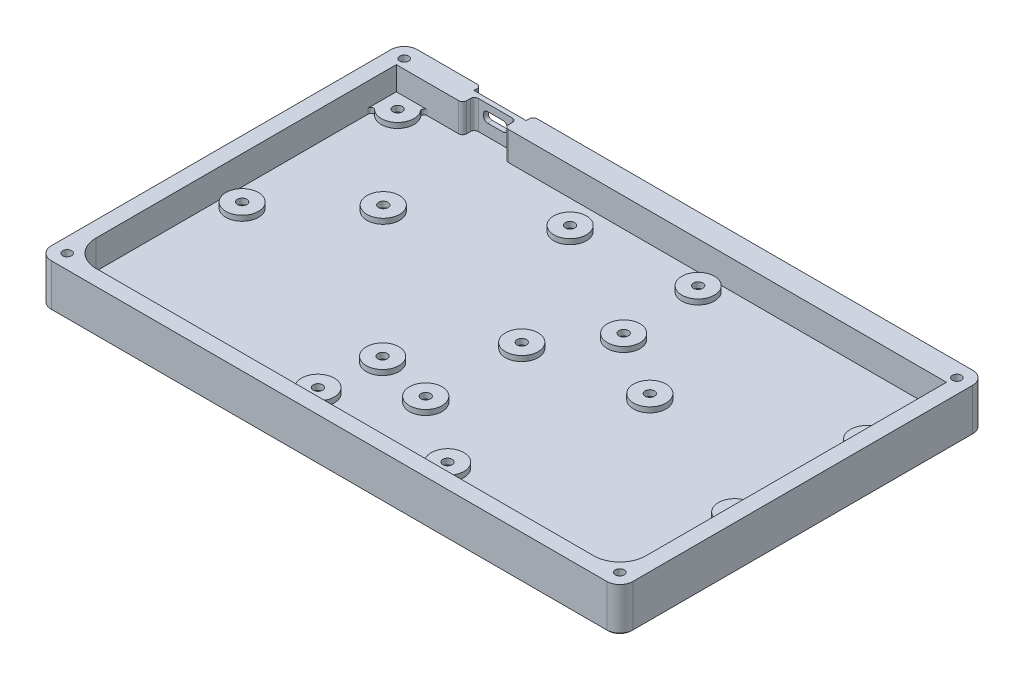
from build123d import *

# Parameters (mm, degrees)
SKETCH1_W                                      = 222.53
SKETCH1_H                                      = 140
BASEPLATE_DEPTH                                = 5.6
SKETCH2_W                                      = 222.53
SKETCH2_H                                      = 140
SIDEWALLS_DEPTH                                = 11
SKETCH3_W                                      = 16
SKETCH3_H                                      = 4.5
USB_RELIEF_DEPTH                               = 11
SKETCH6_R                                      = 6.25
PCB_SUPPORT_DEPTH                              = 2
SKETCH15_W                                     = 6
SKETCH15_H                                     = 5.5
CORNER_FILL_DEPTH                              = 2
FILLET3_R                                      = 1
NUT_START                                      = -0.2
SKETCH4_W                                      = 5.8
SKETCH4_H                                      = 5.8
NUT_CUTOUT_DEPTH                               = 1.8
THIN_USB_WALL_REACH                            = 8.3
THIN_START                                     = -1.8
M3_CLEARANCE_HOLE1_D                           = 3.6
M3_CLEARANCE_HOLE1_DEPTH                       = 2.418450886
M3_CLEARANCE_HOLE1_TIP                         = 1.081549114
CSK_FOR_M3_FLAT_HEAD_MACHINE_SCREW1_AT_2_COUNT = 2
CSK_FOR_M3_FLAT_HEAD_MACHINE_SCREW1_AT_2_PITCH = 211.53
CSK_FOR_M3_FLAT_HEAD_MACHINE_SCREW1_AT_3_COUNT = 2
CSK_FOR_M3_FLAT_HEAD_MACHINE_SCREW1_AT_3_PITCH = 247.761863288
CSK_FOR_M3_FLAT_HEAD_MACHINE_SCREW1_AT_4_COUNT = 2
CSK_FOR_M3_FLAT_HEAD_MACHINE_SCREW1_AT_4_PITCH = 129
USB_PORT_REACH                                 = 139.3
FILLET1_R                                      = 5
FILLET2_R                                      = 1.5
SKETCH13_W                                     = 200
SKETCH13_H                                     = 120
CUT_EXTRUDE1_DEPTH                             = 2.6
CHAMFER1_SIZE                                  = 0.5


with BuildPart() as part:
    # Sketch1 → Baseplate (new body)
    with BuildSketch(Plane(origin=(0, 0, 0), x_dir=(1, 0, 0), z_dir=(0, 1, 0))):
        with Locations((111.265, 70)):
            Rectangle(SKETCH1_W, SKETCH1_H)
    extrude(amount=BASEPLATE_DEPTH)

    # Sketch2 → Sidewalls (add)
    with BuildSketch(Plane(origin=(0, 5.6, 0), x_dir=(1, 0, 0), z_dir=(0, 1, 0))):
        with Locations((111.265, 70)):
            Rectangle(SKETCH2_W, SKETCH2_H)
        with BuildLine():
            Line((206.53, 6), (16, 6))
            ThreePointArc((16, 6), (8.928932188, 8.928932188), (6, 16))
            Line((6, 16), (6, 131))
            Line((6, 131), (216.53, 131))
            Line((216.53, 131), (216.53, 16))
            ThreePointArc((216.53, 16), (213.601067812, 8.928932188), (206.53, 6))
        make_face(mode=Mode.SUBTRACT)
    extrude(amount=SIDEWALLS_DEPTH)

    # Sketch3 → USB Relief (cut)
    with BuildSketch(Plane(origin=(0, 16.6, 0), x_dir=(1, 0, 0), z_dir=(0, 1, 0))):
        with Locations((39.38, 133.25)):
            Rectangle(SKETCH3_W, SKETCH3_H)
    extrude(amount=-USB_RELIEF_DEPTH, mode=Mode.SUBTRACT)

    # Sketch6 → PCB Support (add)
    with BuildSketch(Plane(origin=(0, 5.6, 0), x_dir=(1, 0, 0), z_dir=(0, 1, 0))):
        with Locations((12, 125.5)):
            Circle(SKETCH6_R)
        with Locations((83.5, 120)):
            Circle(SKETCH6_R)
        with Locations((41, 91)):
            Circle(SKETCH6_R)
        with Locations((13, 65)):
            Circle(SKETCH6_R)
        with Locations((91, 40.75)):
            Circle(SKETCH6_R)
        with Locations((138.5, 18.125)):
            Circle(SKETCH6_R)
        with Locations((89, 18)):
            Circle(SKETCH6_R)
        with Locations((112.5, 35.75)):
            Circle(SKETCH6_R)
        with Locations((113, 72)):
            Circle(SKETCH6_R)
        with Locations((210, 56.5)):
            Circle(SKETCH6_R)
        with Locations((154.5, 79.5)):
            Circle(SKETCH6_R)
        with Locations((211, 106)):
            Circle(SKETCH6_R)
        with Locations((128, 124.5)):
            Circle(SKETCH6_R)
        with Locations((129.5, 94.5)):
            Circle(SKETCH6_R)
    extrude(amount=PCB_SUPPORT_DEPTH)

    # Sketch15 → Corner Fill (add)
    with BuildSketch(Plane(origin=(0, 5.6, 0), x_dir=(1, 0, 0), z_dir=(0, 1, 0))):
        with Locations((9, 128.25)):
            Rectangle(SKETCH15_W, SKETCH15_H)
    extrude(amount=CORNER_FILL_DEPTH)

    # Fillet3
    fillet3_edges = [part.edges().sort_by_distance(p)[0] for p in [
        (6, 6.6, -123.75),
        (14.968585522, 6.6, -131),
    ]]
    fillet(fillet3_edges, radius=FILLET3_R)

    # Sketch4 → Nut Cutout (cut)
    with BuildSketch(Plane(origin=(0, 5.6, 0), x_dir=(1, 0, 0), z_dir=(0, 1, 0)).offset(NUT_START)):
        with Locations((12, 125.5)):
            Rectangle(SKETCH4_W, SKETCH4_H)
        with Locations((83.5, 120)):
            Rectangle(SKETCH4_W, SKETCH4_H)
        with Locations((13, 65)):
            Rectangle(SKETCH4_W, SKETCH4_H)
        with Locations((91, 40.75)):
            Rectangle(SKETCH4_W, SKETCH4_H)
        with Locations((113, 72)):
            Rectangle(SKETCH4_W, SKETCH4_H)
        with Locations((138.5, 18.125)):
            Rectangle(SKETCH4_W, SKETCH4_H)
        with Locations((89, 18)):
            Rectangle(SKETCH4_W, SKETCH4_H)
        with Locations((210, 56.5)):
            Rectangle(SKETCH4_W, SKETCH4_H)
        with Locations((129.5, 94.5)):
            Rectangle(SKETCH4_W, SKETCH4_H)
        with Locations((128, 124.5)):
            Rectangle(SKETCH4_W, SKETCH4_H)
        with Locations((211, 106)):
            Rectangle(SKETCH4_W, SKETCH4_H)
        with Locations((41, 91)):
            Rectangle(SKETCH4_W, SKETCH4_H)
        with Locations((112.5, 35.75)):
            Rectangle(SKETCH4_W, SKETCH4_H)
        with Locations((154.5, 79.5)):
            Rectangle(SKETCH4_W, SKETCH4_H)
    extrude(amount=-NUT_CUTOUT_DEPTH, mode=Mode.SUBTRACT)

    # Sketch8 → Thin USB Wall (cut, up to next)
    with BuildSketch(Plane.XY.offset(-135.5).offset(THIN_START), mode=Mode.PRIVATE) as thin_usb_wall_sk1:
        Polygon((31.38, 5.6), (47.38, 5.6), (49.38, 5.6), (49.38, 16.6), (47.38, 16.6), (31.38, 16.6), (29.38, 16.6), (29.38, 5.6), align=None)
    thin_usb_wall_tool1 = extrude(thin_usb_wall_sk1.sketch, amount=-THIN_USB_WALL_REACH, mode=Mode.PRIVATE) & part.part
    add(thin_usb_wall_tool1.solids().sort_by_distance((39.38, 11.1, -137.3))[0], mode=Mode.SUBTRACT)

    # M3 Clearance Hole1
    with Locations(Plane(origin=(12, 7.6, -125.5), x_dir=(0, 0, 1), z_dir=(0, 1, 0))):
        with Locations((0, 0), (53.5, 101), (84.75, 79), (107.5, 77), (107.375, 126.5), (69, 198), (5.5, 71.5), (1, 116), (19.5, 199), (31, 117.5), (60.5, 1), (34.5, 29), (89.75, 100.5), (46, 142.5)):
            Hole(M3_CLEARANCE_HOLE1_D / 2, depth=M3_CLEARANCE_HOLE1_DEPTH)
            with Locations((0, 0, -(M3_CLEARANCE_HOLE1_DEPTH + M3_CLEARANCE_HOLE1_TIP / 2))):  # 118° drill point
                Cone(0, M3_CLEARANCE_HOLE1_D / 2, M3_CLEARANCE_HOLE1_TIP, mode=Mode.SUBTRACT)

    # Sketch11 → CSK for M3 Flat Head Machine Screw1 (revolve, cut)
    with BuildSketch(Plane(origin=(217.03, 0, -5.5), x_dir=(0, 0, -1), z_dir=(1, 0, 0))):
        Polygon((0, 0), (0, 16.6), (1.7, 16.6), (1.7, 3.45), (3.15, 2), (3.15, 0), align=None)
    csk_for_m3_flat_head_machine_screw1 = revolve(axis=Axis((217.03, -6.35, -5.5), (0, 1, 0)), mode=Mode.SUBTRACT)

    # CSK for M3 Flat Head Machine Screw1 at 2: CSK for M3 Flat Head Machine Screw1 ×2
    with Locations(*[(-i * CSK_FOR_M3_FLAT_HEAD_MACHINE_SCREW1_AT_2_PITCH, 0, 0) for i in range(1, CSK_FOR_M3_FLAT_HEAD_MACHINE_SCREW1_AT_2_COUNT)]):
        add(csk_for_m3_flat_head_machine_screw1, mode=Mode.SUBTRACT)

    # CSK for M3 Flat Head Machine Screw1 at 3: CSK for M3 Flat Head Machine Screw1 ×2
    with Locations(*[Vector(-0.853763356, 0, -0.520661244) * (i * CSK_FOR_M3_FLAT_HEAD_MACHINE_SCREW1_AT_3_PITCH) for i in range(1, CSK_FOR_M3_FLAT_HEAD_MACHINE_SCREW1_AT_3_COUNT)]):
        add(csk_for_m3_flat_head_machine_screw1, mode=Mode.SUBTRACT)

    # CSK for M3 Flat Head Machine Screw1 at 4: CSK for M3 Flat Head Machine Screw1 ×2
    with Locations(*[(0, 0, -i * CSK_FOR_M3_FLAT_HEAD_MACHINE_SCREW1_AT_4_PITCH) for i in range(1, CSK_FOR_M3_FLAT_HEAD_MACHINE_SCREW1_AT_4_COUNT)]):
        add(csk_for_m3_flat_head_machine_screw1, mode=Mode.SUBTRACT)

    # Sketch12 → USB Port (cut, up to next)
    with BuildSketch(Plane(origin=(0, 0, -137.3), x_dir=(-1, 0, 0), z_dir=(0, 0, -1)), mode=Mode.PRIVATE) as usb_port_sk1:
        with BuildLine():
            Line((-42.38, 14), (-36.38, 14))
            ThreePointArc((-36.38, 14), (-35.319339828, 13.560660172), (-34.88, 12.5))
            Line((-34.88, 12.5), (-34.88, 11.7))
            ThreePointArc((-34.88, 11.7), (-35.319339828, 10.639339828), (-36.38, 10.2))
            Line((-36.38, 10.2), (-42.38, 10.2))
            ThreePointArc((-42.38, 10.2), (-43.440660172, 10.639339828), (-43.88, 11.7))
            Line((-43.88, 11.7), (-43.88, 12.5))
            ThreePointArc((-43.88, 12.5), (-43.440660172, 13.560660172), (-42.38, 14))
        make_face()
    usb_port_tool1 = extrude(usb_port_sk1.sketch, amount=-USB_PORT_REACH, mode=Mode.PRIVATE) & part.part
    add(usb_port_tool1.solids().sort_by_distance((39.38, 12.1, -137.3))[0], mode=Mode.SUBTRACT)

    # Fillet1
    fillet1_edges = [part.edges().sort_by_distance(p)[0] for p in [
        (0, 8.3, -140),
        (222.53, 8.3, -140),
        (222.53, 8.3, 0),
        (0, 8.3, 0),
    ]]
    fillet(fillet1_edges, radius=FILLET1_R)

    # Fillet2
    fillet2_edges = [part.edges().sort_by_distance(p)[0] for p in [
        (29.38, 11.1, -140),
        (49.38, 11.1, -140),
        (47.38, 11.1, -131),
        (47.38, 11.1, -135.5),
        (31.38, 11.1, -135.5),
        (31.38, 11.1, -131),
    ]]
    fillet(fillet2_edges, radius=FILLET2_R)

    # Sketch13 → Cut-Extrude1 (cut)
    with BuildSketch(Plane.XZ):
        with Locations((111.265, -70)):
            Rectangle(SKETCH13_W, SKETCH13_H)
    extrude(amount=-CUT_EXTRUDE1_DEPTH, mode=Mode.SUBTRACT)

    # Chamfer1
    chamfer1_edges = [part.edges().sort_by_distance(p)[0] for p in [
        (217.03, 0, -131.35),
        (5.5, 0, -131.35),
        (5.5, 0, -2.35),
        (217.03, 0, -2.35),
        (111.265, 0, -140),
        (0, 0, -70),
        (222.53, 0, -70),
        (111.265, 0, 0),
        (1.464466094, 0, -138.535533906),
        (1.464466094, 0, -1.464466094),
        (221.065533906, 0, -1.464466094),
        (221.065533906, 0, -138.535533906),
        (11.265, 0, -70),
        (111.265, 0, -130),
        (211.265, 0, -70),
        (111.265, 0, -10),
    ]]
    chamfer(chamfer1_edges, length=CHAMFER1_SIZE)


solid = part.part
